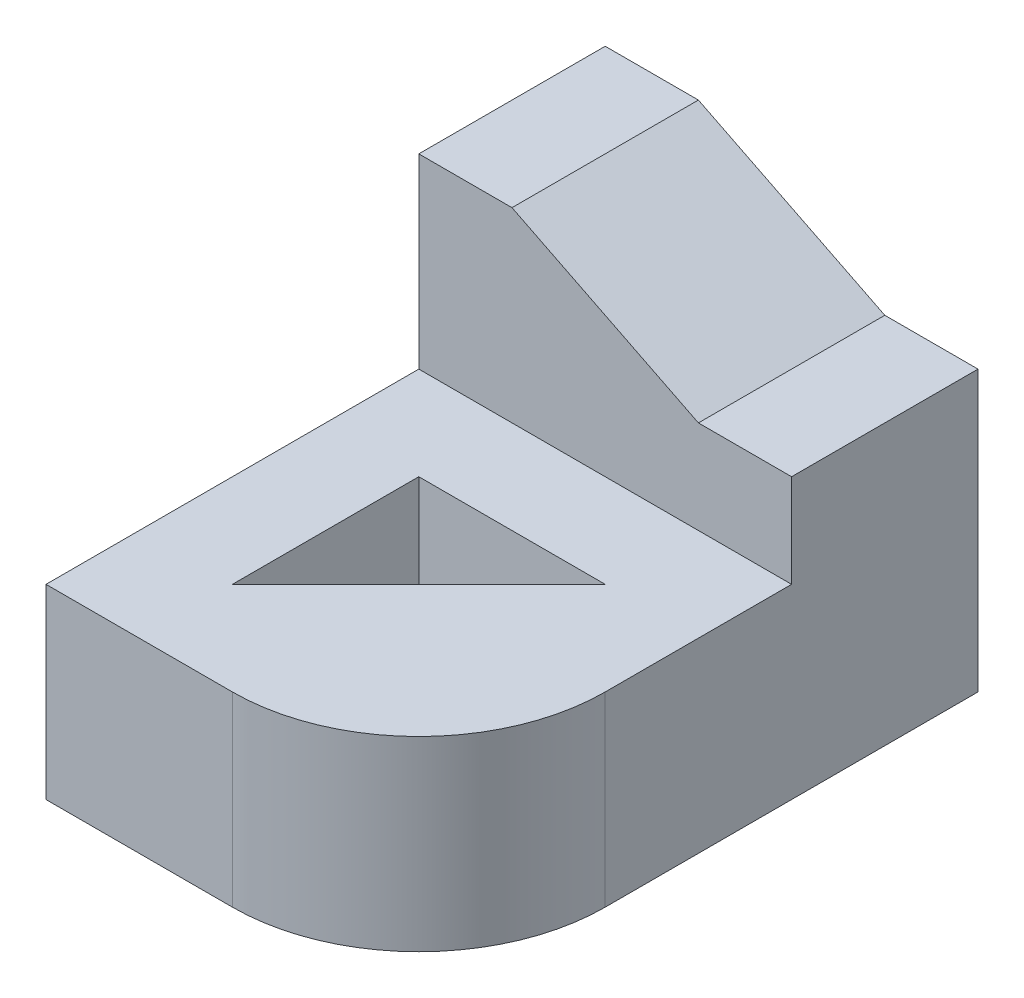
from build123d import *

# Parameters (mm, degrees)
EXTRUDE_1_DEPTH     = 10
SKETCH_1_3_W        = 20
SKETCH_1_3_H        = 10
EXTRUDE_2_DEPTH     = 20
CUT_EXTRUDE_1_DEPTH = 20
FILLET_1_R          = 10


with BuildPart() as part:
    # 草圖1 → 填料-伸長1 (new body)
    with BuildSketch(Plane(origin=(0, 0, 0), x_dir=(1, 0, 0), z_dir=(0, 1, 0))):
        Polygon((-5, 10), (-10, 10), (-10, -10), (10, -10), (10, 10), (5, 10), align=None)
        Polygon((-5, 5), (5, 5), (-5, -5), align=None, mode=Mode.SUBTRACT)
    extrude(amount=EXTRUDE_1_DEPTH)

    # 草圖1<3> → 填料-伸長2 (add)
    with BuildSketch(Plane(origin=(0, 0, 0), x_dir=(1, 0, 0), z_dir=(0, 1, 0))):
        with Locations((0, 15)):
            Rectangle(SKETCH_1_3_W, SKETCH_1_3_H)
    extrude(amount=EXTRUDE_2_DEPTH)

    # 草圖2 → 除料-伸長1 (cut)
    with BuildSketch(Plane.XY.offset(-10)):
        Polygon((-5, 20), (5, 15), (10, 15), (10, 20), align=None)
    extrude(amount=-CUT_EXTRUDE_1_DEPTH, mode=Mode.SUBTRACT)

    # 圓角1
    fillet_1_edges = [part.edges().sort_by_distance(p)[0] for p in [
        (10, 5, 10),
    ]]
    fillet(fillet_1_edges, radius=FILLET_1_R)


solid = part.part
